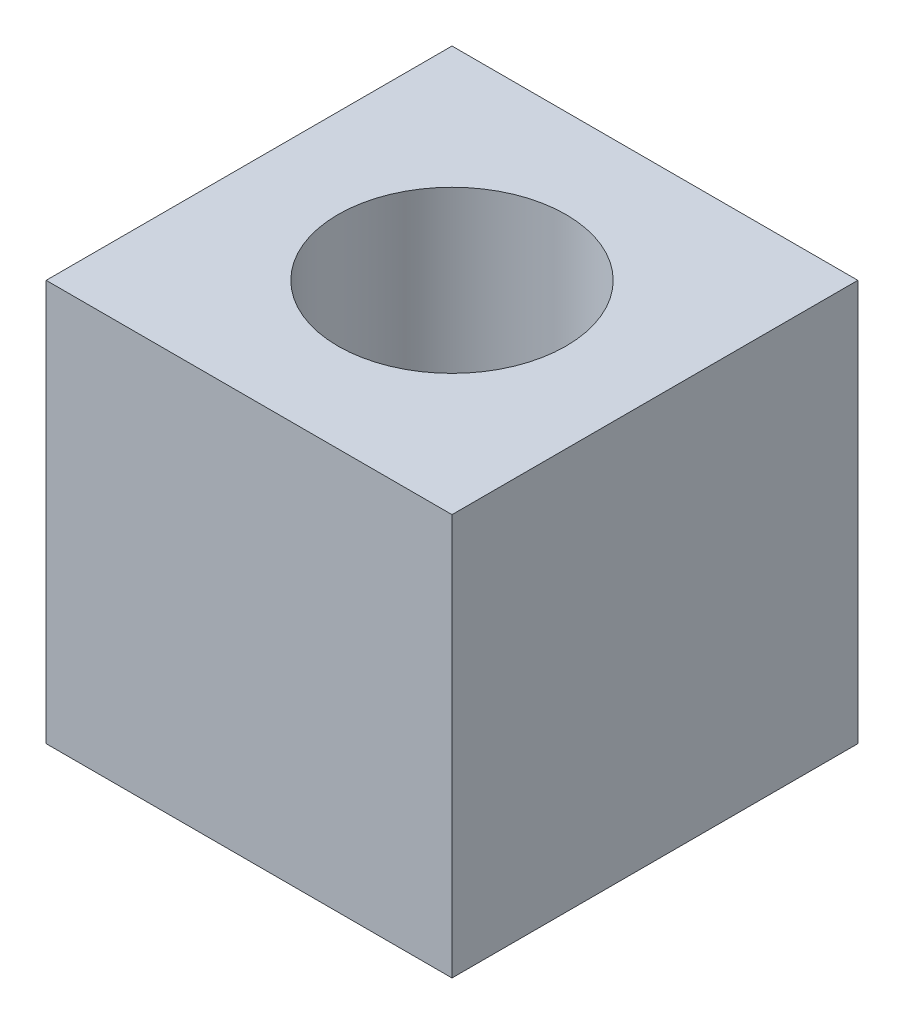
from build123d import *

# Parameters (mm, degrees)
SKETCH1_W           = 11.303
SKETCH1_H           = 11.303
SKETCH1_R           = 3.175
BOSS_EXTRUDE1_DEPTH = 11.176
CUT_EXTRUDE1_REACH  = 19.018
CUT_EXTRUDE1_START  = -5.842
SKETCH2_R           = 3.556
SKETCH2_R_2         = 3.175


with BuildPart() as part:
    # Sketch1 → Boss-Extrude1 (new body)
    with BuildSketch(Plane(origin=(0, 0, 0), x_dir=(1, 0, 0), z_dir=(0, 1, 0))):
        with Locations((5.6515, 5.6515)):
            Rectangle(SKETCH1_W, SKETCH1_H)
        with Locations((5.6515, 5.6515)):
            Circle(SKETCH1_R, mode=Mode.SUBTRACT)
    extrude(amount=BOSS_EXTRUDE1_DEPTH)

    # Sketch2 → Cut-Extrude1 (cut, up to next)
    with BuildSketch(Plane(origin=(0, 11.176, 0), x_dir=(1, 0, 0), z_dir=(0, 1, 0)).offset(CUT_EXTRUDE1_START), mode=Mode.PRIVATE) as cut_extrude1_sk1:
        with Locations((5.6515, 5.6515)):
            Circle(SKETCH2_R)
        with Locations((5.6515, 5.6515)):
            Circle(SKETCH2_R_2, mode=Mode.SUBTRACT)
    cut_extrude1_tool1 = extrude(cut_extrude1_sk1.sketch, amount=-CUT_EXTRUDE1_REACH, mode=Mode.PRIVATE) & part.part
    add(cut_extrude1_tool1.solids().sort_by_distance((2.196079, 5.334, -5.6515))[0], mode=Mode.SUBTRACT)


solid = part.part
